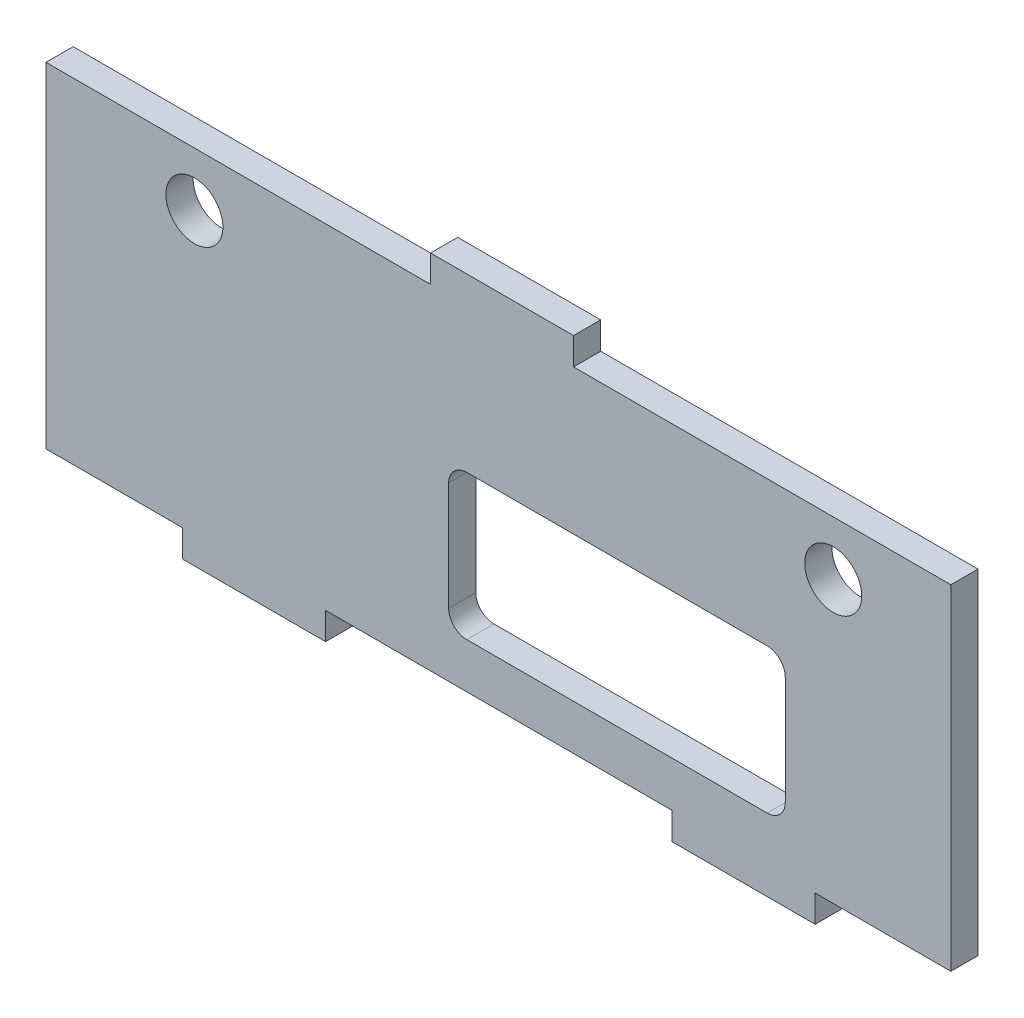
from build123d import *

# Parameters (mm, degrees)
CROQUIS1_R              = 3.15
SALIENTE_EXTRUIR1_DEPTH = 3


with BuildPart() as part:
    # Croquis1 → Saliente-Extruir1 (new body)
    with BuildSketch(Plane.XY):
        Polygon((8.3, 21.5), (-7.5, 21.5), (-7.5, 18.5), (-50, 18.5), (-50, -18.5), (-34.9, -18.5), (-34.9, -21.5), (-19.1, -21.5), (-19.1, -18.5), (19.2, -18.5), (19.2, -21.5), (35, -21.5), (35, -18.5), (50, -18.5), (50, 18.5), (8.3, 18.5), align=None)
        with BuildLine():
            ThreePointArc((-5.5, 0.5), (-4.914213562, 1.914213562), (-3.5, 2.5))
            Line((-3.5, 2.5), (29.7, 2.5))
            ThreePointArc((29.7, 2.5), (31.114213562, 1.914213562), (31.7, 0.5))
            Line((31.7, 0.5), (31.7, -11.5))
            ThreePointArc((31.7, -11.5), (31.114213562, -12.914213562), (29.7, -13.5))
            Line((29.7, -13.5), (-3.5, -13.5))
            ThreePointArc((-3.5, -13.5), (-4.914213562, -12.914213562), (-5.5, -11.5))
            Line((-5.5, -11.5), (-5.5, 0.5))
        make_face(mode=Mode.SUBTRACT)
        with Locations((-33.6, 12.5)):
            Circle(CROQUIS1_R, mode=Mode.SUBTRACT)
        with Locations((37, 12.5)):
            Circle(CROQUIS1_R, mode=Mode.SUBTRACT)
    extrude(amount=SALIENTE_EXTRUIR1_DEPTH)


solid = part.part
